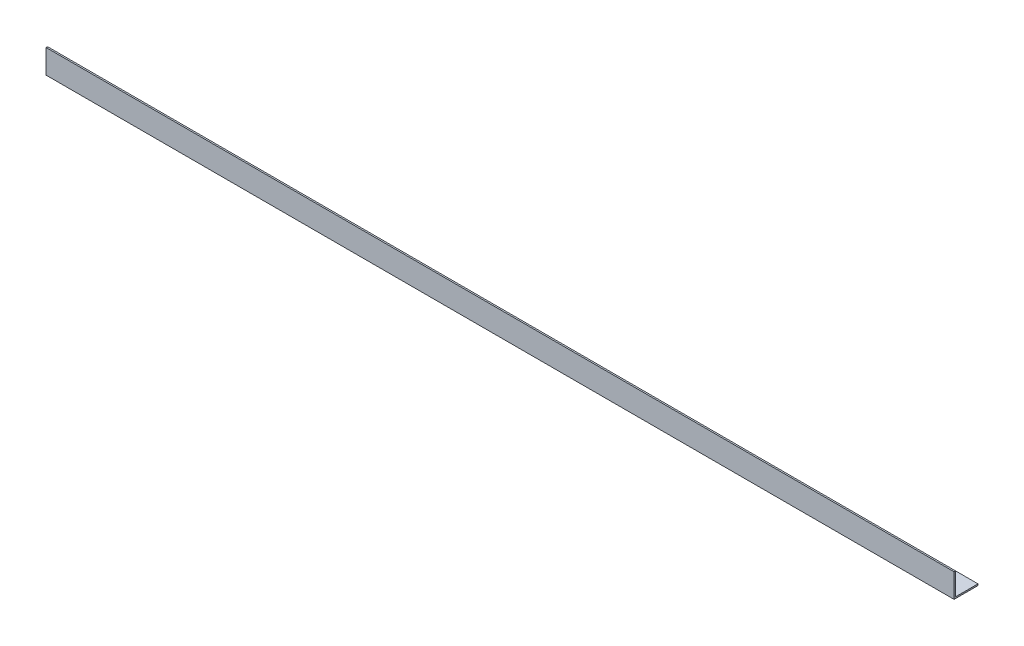
from build123d import *

# Parameters (mm, degrees)
SALIENTE_EXTRUIR1_DEPTH = 607


with BuildPart() as part:
    # Croquis1 → Saliente-Extruir1 (new body)
    with BuildSketch(Plane(origin=(0, 0, 0), x_dir=(0, 0, -1), z_dir=(1, 0, 0))):
        Polygon((0, 16), (0, 0), (16, 0), (16, 1), (1, 1), (1, 16), align=None)
    extrude(amount=SALIENTE_EXTRUIR1_DEPTH)


solid = part.part
